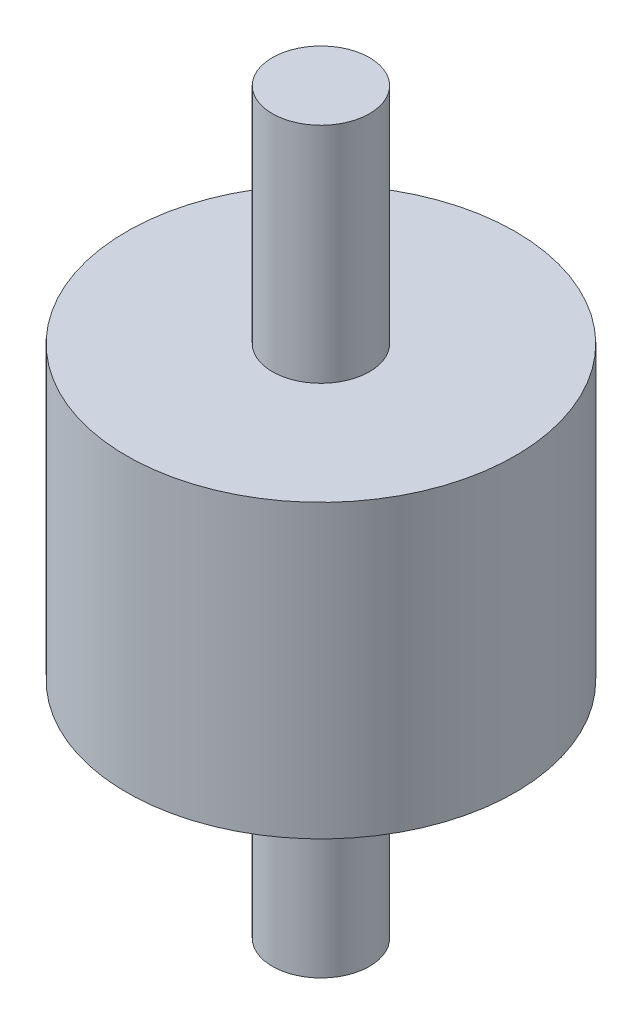
from build123d import *


with BuildPart() as part:
    # Sketch1 → Revolve1 (revolve)
    with BuildSketch(Plane.XY):
        Polygon((0, 38), (5, 38), (5, 15), (20, 15), (20, 0), (0, 0), align=None)
    revolve1 = revolve(axis=Axis((0, 0, 0), (0, 1, 0)))

    # Mirror1: Revolve1 across plane
    add(revolve1.mirror(Plane(origin=(20, 0, 0), x_dir=(0, 0, 1), z_dir=(0, -1, 0))))


solid = part.part
